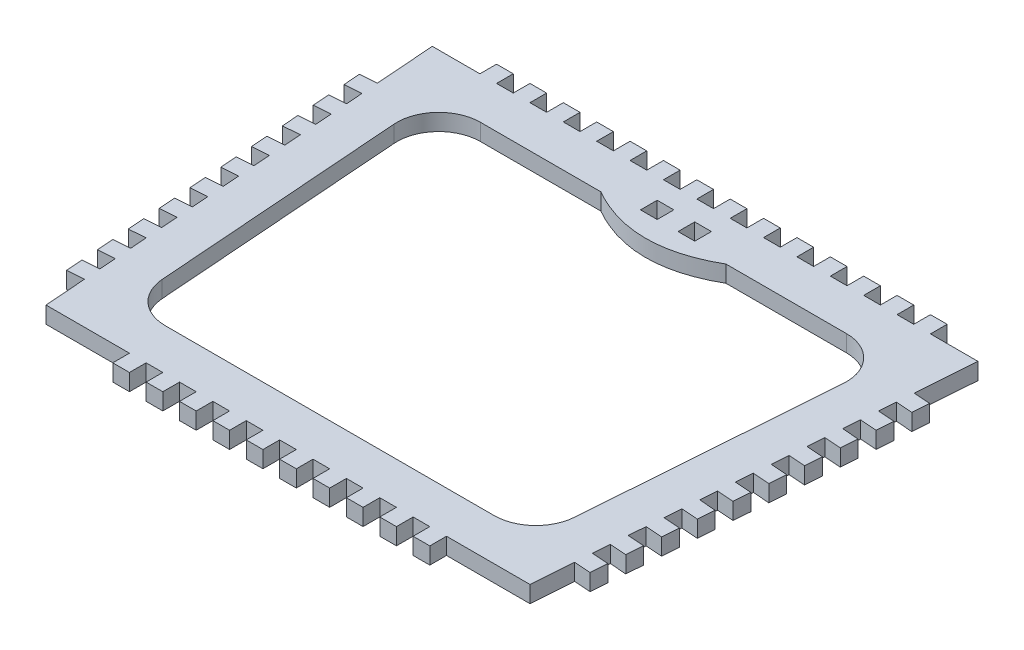
from build123d import *

# Parameters (mm, degrees)
BOSS_EXTRUDE1_DEPTH = 4
SKETCH2_W           = 4
SKETCH2_H           = 4
BOSS_EXTRUDE2_DEPTH = 4
SKETCH4_W           = 4
SKETCH4_H           = 4
CUT_EXTRUDE1_DEPTH  = 10
BOSS_EXTRUDE3_DEPTH = 4


with BuildPart() as part:
    # Sketch1 → Boss-Extrude1 (new body)
    with BuildSketch(Plane(origin=(0, 0, 0), x_dir=(1, 0, 0), z_dir=(0, 1, 0))):
        Polygon((-65.4, 43.024336283), (0, 43.024336283), (65.4, 43.024336283), (58, -56.975663717), (0, -56.975663717), (-58, -56.975663717), align=None)
    extrude(amount=BOSS_EXTRUDE1_DEPTH)

    # Sketch2 → Boss-Extrude2 (add)
    with BuildSketch(Plane(origin=(0, 4, 0), x_dir=(1, 0, 0), z_dir=(0, 1, 0))):
        with Locations((-4, 45.024336283)):
            Rectangle(SKETCH2_W, SKETCH2_H)
        with Locations((-12, 45.024336283)):
            Rectangle(SKETCH2_W, SKETCH2_H)
        with Locations((-20, 45.024336283)):
            Rectangle(SKETCH2_W, SKETCH2_H)
        with Locations((-28, 45.024336283)):
            Rectangle(SKETCH2_W, SKETCH2_H)
        with Locations((-36, 45.024336283)):
            Rectangle(SKETCH2_W, SKETCH2_H)
        with Locations((-44, 45.024336283)):
            Rectangle(SKETCH2_W, SKETCH2_H)
        with Locations((-52, 45.024336283)):
            Rectangle(SKETCH2_W, SKETCH2_H)
        with Locations((52, 45.024336283)):
            Rectangle(SKETCH2_W, SKETCH2_H)
        with Locations((44, 45.024336283)):
            Rectangle(SKETCH2_W, SKETCH2_H)
        with Locations((36, 45.024336283)):
            Rectangle(SKETCH2_W, SKETCH2_H)
        with Locations((28, 45.024336283)):
            Rectangle(SKETCH2_W, SKETCH2_H)
        with Locations((20, 45.024336283)):
            Rectangle(SKETCH2_W, SKETCH2_H)
        with Locations((12, 45.024336283)):
            Rectangle(SKETCH2_W, SKETCH2_H)
        with Locations((4, 45.024336283)):
            Rectangle(SKETCH2_W, SKETCH2_H)
        with Locations((-4, -58.975663717)):
            Rectangle(SKETCH2_W, SKETCH2_H)
        with Locations((-12, -58.975663717)):
            Rectangle(SKETCH2_W, SKETCH2_H)
        with Locations((-20, -58.975663717)):
            Rectangle(SKETCH2_W, SKETCH2_H)
        with Locations((-28, -58.975663717)):
            Rectangle(SKETCH2_W, SKETCH2_H)
        with Locations((-36, -58.975663717)):
            Rectangle(SKETCH2_W, SKETCH2_H)
        with Locations((36, -58.975663717)):
            Rectangle(SKETCH2_W, SKETCH2_H)
        with Locations((28, -58.975663717)):
            Rectangle(SKETCH2_W, SKETCH2_H)
        with Locations((20, -58.975663717)):
            Rectangle(SKETCH2_W, SKETCH2_H)
        with Locations((12, -58.975663717)):
            Rectangle(SKETCH2_W, SKETCH2_H)
        with Locations((4, -58.975663717)):
            Rectangle(SKETCH2_W, SKETCH2_H)
    extrude(amount=-BOSS_EXTRUDE2_DEPTH)

    # Sketch4 → Cut-Extrude1 (cut)
    with BuildSketch(Plane(origin=(0, 4, 0), x_dir=(1, 0, 0), z_dir=(0, 1, 0))):
        with BuildLine():
            Line((-53.838046701, 22.28635412), (-49.398046701, -37.71364588))
            ThreePointArc((-49.398046701, -37.71364588), (-46.230466427, -44.303003672), (-39.425314762, -46.975663717))
            Line((-39.425314762, -46.975663717), (39.425314762, -46.975663717))
            ThreePointArc((39.425314762, -46.975663717), (46.230466427, -44.303003672), (49.398046701, -37.71364588))
            Line((49.398046701, -37.71364588), (53.838046701, 22.28635412))
            ThreePointArc((53.838046701, 22.28635412), (51.192654717, 29.829487948), (43.865314762, 33.024336283))
            Line((43.865314762, 33.024336283), (15, 33.024336283))
            add(Edge.make_bspline(
                [(-15, 33.024336283), (0, 24.430558872), (15, 33.024336283)],
                knots=[0, 0, 0, 1, 1, 1], degree=2))
            Line((-15, 33.024336283), (-43.865314762, 33.024336283))
            ThreePointArc((-43.865314762, 33.024336283), (-51.192654717, 29.829487948), (-53.838046701, 22.28635412))
        make_face()
        with Locations((-4.5, 36.024336283)):
            Rectangle(SKETCH4_W, SKETCH4_H)
        with Locations((4.5, 36.024336283)):
            Rectangle(SKETCH4_W, SKETCH4_H)
    extrude(amount=-CUT_EXTRUDE1_DEPTH, mode=Mode.SUBTRACT)

    # Sketch5 → Boss-Extrude3 (add)
    with BuildSketch(Plane(origin=(0, 4, 0), x_dir=(1, 0, 0), z_dir=(0, 1, 0))):
        Polygon((-59.62356076, -35.035653451), (-63.612653535, -35.330846316), (-63.31746067, -39.319939092), (-59.328367894, -39.024746227), align=None)
        Polygon((-59.033175029, -43.013839002), (-63.022267804, -43.309031868), (-62.727074939, -47.298124643), (-58.737982163, -47.002931778), align=None)
        Polygon((-60.21394649, -27.0574679), (-64.203039266, -27.352660765), (-63.907846401, -31.341753541), (-59.918753625, -31.046560676), align=None)
        Polygon((-60.804332221, -19.079282349), (-64.793424997, -19.374475214), (-64.498232131, -23.36356799), (-60.509139356, -23.068375124), align=None)
        Polygon((-61.394717952, -11.101096798), (-65.383810728, -11.396289663), (-65.088617862, -15.385382439), (-61.099525087, -15.090189573), align=None)
        Polygon((-61.985103683, -3.122911246), (-65.974196458, -3.418104112), (-65.679003593, -7.407196887), (-61.689910817, -7.112004022), align=None)
        Polygon((-62.575489414, 4.855274305), (-66.564582189, 4.560081439), (-66.269389324, 0.570988664), (-62.280296548, 0.866181529), align=None)
        Polygon((-63.165875144, 12.833459856), (-67.15496792, 12.538266991), (-66.859775055, 8.549174215), (-62.870682279, 8.84436708), align=None)
        Polygon((-63.756260875, 20.811645407), (-67.745353651, 20.516452542), (-67.450160785, 16.527359766), (-63.46106801, 16.822552632), align=None)
        Polygon((-64.346646606, 28.789830958), (-68.335739382, 28.494638093), (-68.040546516, 24.505545317), (-64.051453741, 24.800738183), align=None)
        Polygon((64.051453741, 24.800738183), (64.346646606, 28.789830958), (68.335739382, 28.494638093), (68.040546516, 24.505545317), align=None)
        Polygon((63.46106801, 16.822552632), (63.756260875, 20.811645407), (67.745353651, 20.516452542), (67.450160785, 16.527359766), align=None)
        Polygon((62.870682279, 8.84436708), (63.165875144, 12.833459856), (67.15496792, 12.538266991), (66.859775055, 8.549174215), align=None)
        Polygon((62.280296548, 0.866181529), (62.575489414, 4.855274305), (66.564582189, 4.560081439), (66.269389324, 0.570988664), align=None)
        Polygon((61.689910817, -7.112004022), (61.985103683, -3.122911246), (65.974196458, -3.418104112), (65.679003593, -7.407196887), align=None)
        Polygon((61.099525087, -15.090189573), (61.394717952, -11.101096798), (65.383810728, -11.396289663), (65.088617862, -15.385382439), align=None)
        Polygon((60.509139356, -23.068375124), (60.804332221, -19.079282349), (64.793424997, -19.374475214), (64.498232131, -23.36356799), align=None)
        Polygon((59.918753625, -31.046560676), (60.21394649, -27.0574679), (64.203039266, -27.352660765), (63.907846401, -31.341753541), align=None)
        Polygon((58.737982163, -47.002931778), (59.033175029, -43.013839002), (63.022267804, -43.309031868), (62.727074939, -47.298124643), align=None)
        Polygon((59.328367894, -39.024746227), (59.62356076, -35.035653451), (63.612653535, -35.330846316), (63.31746067, -39.319939092), align=None)
    extrude(amount=-BOSS_EXTRUDE3_DEPTH)


solid = part.part
